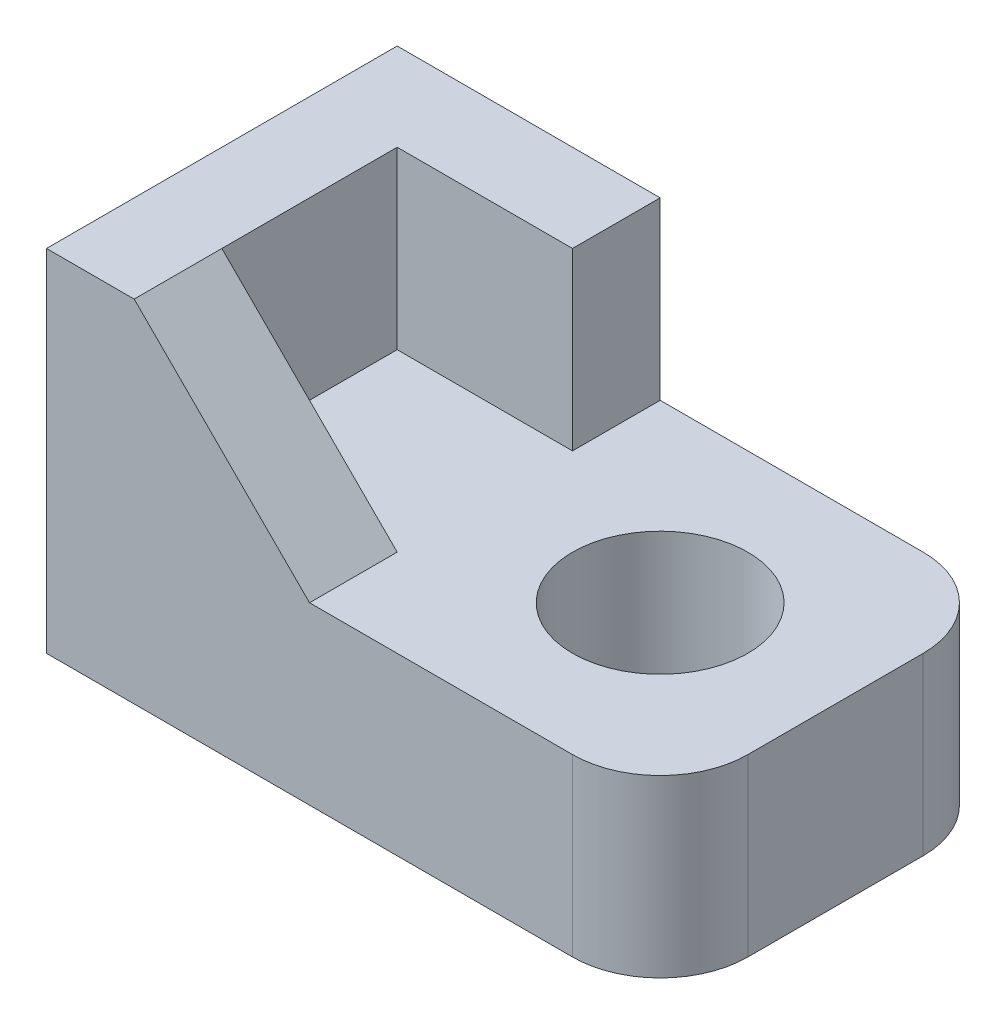
from build123d import *

# Parameters (mm, degrees)
SKETCH_1_R          = 1
EXTRUDE_1_DEPTH     = 2
EXTRUDE_2_DEPTH     = 4
CUT_EXTRUDE_1_DEPTH = 1


with BuildPart() as part:
    # 草圖1 → 填料-伸長1 (new body)
    with BuildSketch(Plane(origin=(0, 0, 0), x_dir=(1, 0, 0), z_dir=(0, 1, 0))):
        with BuildLine():
            Line((0, -2), (0, 2))
            Line((0, 2), (6, 2))
            ThreePointArc((6, 2), (6.707106781, 1.707106781), (7, 1))
            Line((7, 1), (7, 0))
            Line((7, 0), (7, -1))
            ThreePointArc((7, -1), (6.707106781, -1.707106781), (6, -2))
            Line((6, -2), (0, -2))
        make_face()
        with Locations((5, 0)):
            Circle(SKETCH_1_R, mode=Mode.SUBTRACT)
    extrude(amount=EXTRUDE_1_DEPTH)

    # 草圖4 → 填料-伸長2 (add)
    with BuildSketch(Plane(origin=(0, 0, 0), x_dir=(1, 0, 0), z_dir=(0, 1, 0))):
        Polygon((0, 0), (0, 2), (3, 2), (3, 1), (1, 1), (1, -1), (3, -1), (3, -2), (0, -2), align=None)
    extrude(amount=EXTRUDE_2_DEPTH)

    # 草圖5 → 除料-伸長1 (cut)
    with BuildSketch(Plane.XY.offset(2)):
        Polygon((3, 2), (1, 4), (3, 4), align=None)
    extrude(amount=-CUT_EXTRUDE_1_DEPTH, mode=Mode.SUBTRACT)


solid = part.part
